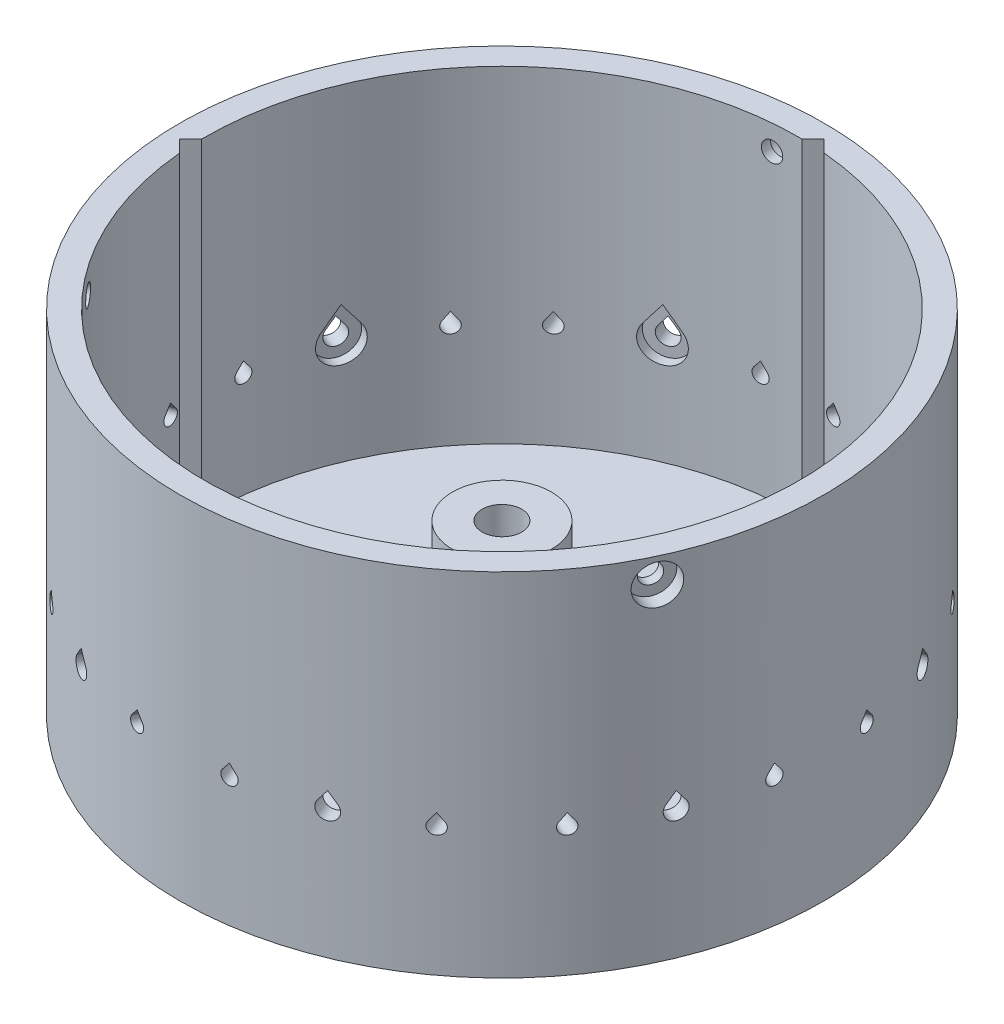
from build123d import *

# Parameters (mm, degrees)
BOSS_EXTRUDE1_START = -119.238207
SKETCH6_R           = 2.5
BOSS_EXTRUDE1_DEPTH = 238.476414
CIRPATTERN2_COUNT   = 4
CIRPATTERN2_ANGLE   = 135
SKETCH9_R           = 60
BOSS_EXTRUDE2_DEPTH = 5
CUT_EXTRUDE1_REACH  = 73
SKETCH10_R          = 15
CUT_EXTRUDE3_DEPTH  = 66
SKETCH17_R          = 160
SKETCH17_R_2        = 65
CUT_EXTRUDE4_DEPTH  = 37.0000001
CUT_EXTRUDE5_START  = -7.608799
CUT_EXTRUDE5_DEPTH  = 7.608799
CUT_EXTRUDE6_DEPTH  = 7
CIRPATTERN3_COUNT   = 8
SKETCH22_R          = 2
CUT_EXTRUDE8_DEPTH  = 77.380193303
SKETCH23_R          = 4
CUT_EXTRUDE9_DEPTH  = 3
CIRPATTERN4_COUNT   = 3
CUT_EXTRUDE12_DEPTH = 5
CIRPATTERN6_COUNT   = 8


with BuildPart() as part:
    # Sketch1 → Revolve1 (revolve)
    with BuildSketch(Plane.XY):
        with BuildLine():
            Line((120, 0), (156, 0))
            ThreePointArc((156, 0), (158.828427125, -1.171572875), (160, -4))
            ThreePointArc((160, -4), (157.806865016, -19.65910429), (151.396226415, -34.113207547))
            ThreePointArc((151.396226415, -34.113207547), (149.942571725, -35.496629104), (148, -36))
            Line((148, -36), (120, -36))
            Line((120, -36), (120, 0))
        make_face()
    revolve(axis=Axis((0, 0, 0), (0, -1, 0)))



with BuildPart() as body_2:
    # Sketch5 → Revolve2 (revolve)
    with BuildSketch(Plane(origin=(0, 0, 0), x_dir=(0, 0, -1), z_dir=(1, 0, 0))):
        Polygon((60, 0), (65, 0), (65, -31), (81, -31), (81, -36), (65, -36), (65, -71), (60, -71), align=None)
    revolve(axis=Axis((0, 16.243061615, 0), (0, -1, 0)))


with BuildPart() as part_1:
    add(part.part)

    add(body_2.part)  # Boss-Extrude1 merges body 2
    # Sketch6 → Boss-Extrude1 (add)
    with BuildSketch(Plane(origin=(0, 0, 0), x_dir=(0, 0, -1), z_dir=(1, 0, 0)).offset(BOSS_EXTRUDE1_START)):
        with Locations((-16, -33.5)):
            Circle(SKETCH6_R)
        with Locations((16, -33.5)):
            Circle(SKETCH6_R)
    boss_extrude1 = extrude(amount=BOSS_EXTRUDE1_DEPTH)

    # CirPattern2: Boss-Extrude1 ×4 about axis
    cirpattern2_axis = Axis((0, 0, 0), (0, 1, 0))
    for i in range(1, CIRPATTERN2_COUNT):
        add(boss_extrude1.rotate(cirpattern2_axis, i * CIRPATTERN2_ANGLE / (CIRPATTERN2_COUNT - 1)))

    # Sketch8 → Cut-Revolve1 (revolve, cut)
    with BuildSketch(Plane.XY):
        Polygon((0, 0), (0, -91.68650698), (-49.523812272, -91.68650698), (-60, -71), (-60, 0), align=None)
    revolve(axis=Axis((0, 0, 0), (0, -1, 0)), mode=Mode.SUBTRACT)

    # Sketch9 → Boss-Extrude2 (add)
    with BuildSketch(Plane.XZ.offset(71)):
        Circle(SKETCH9_R)
    extrude(amount=-BOSS_EXTRUDE2_DEPTH)

    # Sketch10 → Cut-Extrude1 (cut, up to next)
    with BuildSketch(Plane.XZ.offset(71), mode=Mode.PRIVATE) as cut_extrude1_sk1:
        Circle(SKETCH10_R)
    cut_extrude1_tool1 = extrude(cut_extrude1_sk1.sketch, amount=-CUT_EXTRUDE1_REACH, mode=Mode.PRIVATE) & part_1.part
    add(cut_extrude1_tool1.solids().sort_by_distance((0, -71, 0))[0], mode=Mode.SUBTRACT)

    # Sketch11 → Revolve3 (revolve)
    with BuildSketch(Plane(origin=(0, 0, 0), x_dir=(0, 0, -1), z_dir=(1, 0, 0))):
        Polygon((-7.360428411, -71), (-4, -71), (-4, -37), (-8.047662955, -37), (-10, -37), (-10, -66), (-15, -66), (-15, -71), align=None)
    revolve(axis=Axis((0, -71, 0), (0, 1, 0)))

    # Sketch14 → Cut-Extrude3 (cut)
    with BuildSketch(Plane(origin=(0, 0, 0), x_dir=(1, 0, 0), z_dir=(0, 1, 0))):
        Polygon((2.828427125, 62.225396744), (-62.225396744, -2.828427125), (-58.689862838, -6.363961031), (6.363961031, 58.689862838), align=None)
    extrude(amount=-CUT_EXTRUDE3_DEPTH, mode=Mode.SUBTRACT)

    # Sketch17 → Cut-Extrude4 (cut, through all)
    with BuildSketch(Plane.XZ.offset(36)):
        Circle(SKETCH17_R)
        Circle(SKETCH17_R_2, mode=Mode.SUBTRACT)
    extrude(amount=-CUT_EXTRUDE4_DEPTH, mode=Mode.SUBTRACT)

    # Sketch18 → Cut-Extrude5 (cut)
    with BuildSketch(Plane(origin=(-60.052169613, 0, 24.874423104), x_dir=(0.382683432, 0, 0.923879533), z_dir=(-0.923879533, 0, 0.382683432)).offset(CUT_EXTRUDE5_START)):
        with BuildLine():
            Line((-17.19003001, -44.086857856), (-16, -42.535980552))
            Line((-16, -42.535980552), (-14.80996999, -44.086857856))
            ThreePointArc((-14.80996999, -44.086857856), (-16, -46.5), (-17.19003001, -44.086857856))
        make_face()
        with BuildLine():
            Line((-1.586706681, -43.782477142), (0, -41.714640737))
            Line((0, -41.714640737), (1.586706681, -43.782477142))
            ThreePointArc((1.586706681, -43.782477142), (0, -47), (-1.586706681, -43.782477142))
        make_face()
        with BuildLine():
            Line((14.80996999, -44.086857856), (16, -42.535980552))
            Line((16, -42.535980552), (17.19003001, -44.086857856))
            ThreePointArc((17.19003001, -44.086857856), (16, -46.5), (14.80996999, -44.086857856))
        make_face()
    cut_extrude5 = extrude(amount=CUT_EXTRUDE5_DEPTH, mode=Mode.SUBTRACT)

    # Sketch20 → Cut-Extrude6 (cut)
    with BuildSketch(Plane(origin=(-50.813374288, 0, 21.04758878), x_dir=(0.382683432, 0, 0.923879533), z_dir=(-0.923879533, 0, 0.382683432))):
        with BuildLine():
            Line((-3.173413361, -42.564954284), (0, -38.429281473))
            Line((0, -38.429281473), (3.173413361, -42.564954284))
            ThreePointArc((3.173413361, -42.564954284), (0, -49), (-3.173413361, -42.564954284))
        make_face()
    cut_extrude6 = extrude(amount=CUT_EXTRUDE6_DEPTH, mode=Mode.SUBTRACT)

    # CirPattern3: Cut-Extrude5, Cut-Extrude6 ×8 about axis
    cirpattern3_axis = Axis((0, 0, 0), (0, 1, 0))
    for i in range(1, CIRPATTERN3_COUNT):
        add(cut_extrude5.rotate(cirpattern3_axis, i * 360 / CIRPATTERN3_COUNT), mode=Mode.SUBTRACT)
        add(cut_extrude6.rotate(cirpattern3_axis, i * 360 / CIRPATTERN3_COUNT), mode=Mode.SUBTRACT)

    # Sketch22 → Cut-Extrude8 (cut, through all)
    with BuildSketch(Plane(origin=(20.043022393, 0, -19.320384399), x_dir=(-0.422618262, 0, 0.906307787), z_dir=(-0.906307787, 0, -0.422618262))):
        with Locations((25.980762114, -5)):
            Circle(SKETCH22_R)
    cut_extrude8 = extrude(amount=-CUT_EXTRUDE8_DEPTH, mode=Mode.SUBTRACT)

    # Sketch23 → Cut-Extrude9 (cut)
    with BuildSketch(Plane(origin=(58.910006157, 0, 27.470187013), x_dir=(0.422618262, 0, -0.906307787), z_dir=(0.906307787, 0, 0.422618262))):
        with Locations((0, -5)):
            Circle(SKETCH23_R)
    cut_extrude9 = extrude(amount=-CUT_EXTRUDE9_DEPTH, mode=Mode.SUBTRACT)

    # CirPattern4: Cut-Extrude8, Cut-Extrude9 ×3 about axis
    cirpattern4_axis = Axis((0, 0, 0), (0, 1, 0))
    for i in range(1, CIRPATTERN4_COUNT):
        add(cut_extrude8.rotate(cirpattern4_axis, i * 360 / CIRPATTERN4_COUNT), mode=Mode.SUBTRACT)
        add(cut_extrude9.rotate(cirpattern4_axis, i * 360 / CIRPATTERN4_COUNT), mode=Mode.SUBTRACT)

    # Sketch26 → Cut-Extrude12 (cut)
    with BuildSketch(Plane.XZ.offset(71)):
        with BuildLine():
            Line((-25.980762114, 15), (-2.272077939, 15))
            Line((-2.272077939, 15), (-13.872145314, 26.600067376))
            ThreePointArc((-13.872145314, 26.600067376), (-20.753408115, 21.663241946), (-25.980762114, 15))
        make_face()
    cut_extrude12 = extrude(amount=-CUT_EXTRUDE12_DEPTH, mode=Mode.SUBTRACT)

    # CirPattern6: Cut-Extrude12 ×8 about axis
    cirpattern6_axis = Axis((0, 0, 0), (0, 1, 0))
    for i in range(1, CIRPATTERN6_COUNT):
        add(cut_extrude12.rotate(cirpattern6_axis, i * 360 / CIRPATTERN6_COUNT), mode=Mode.SUBTRACT)


solid = part_1.part
